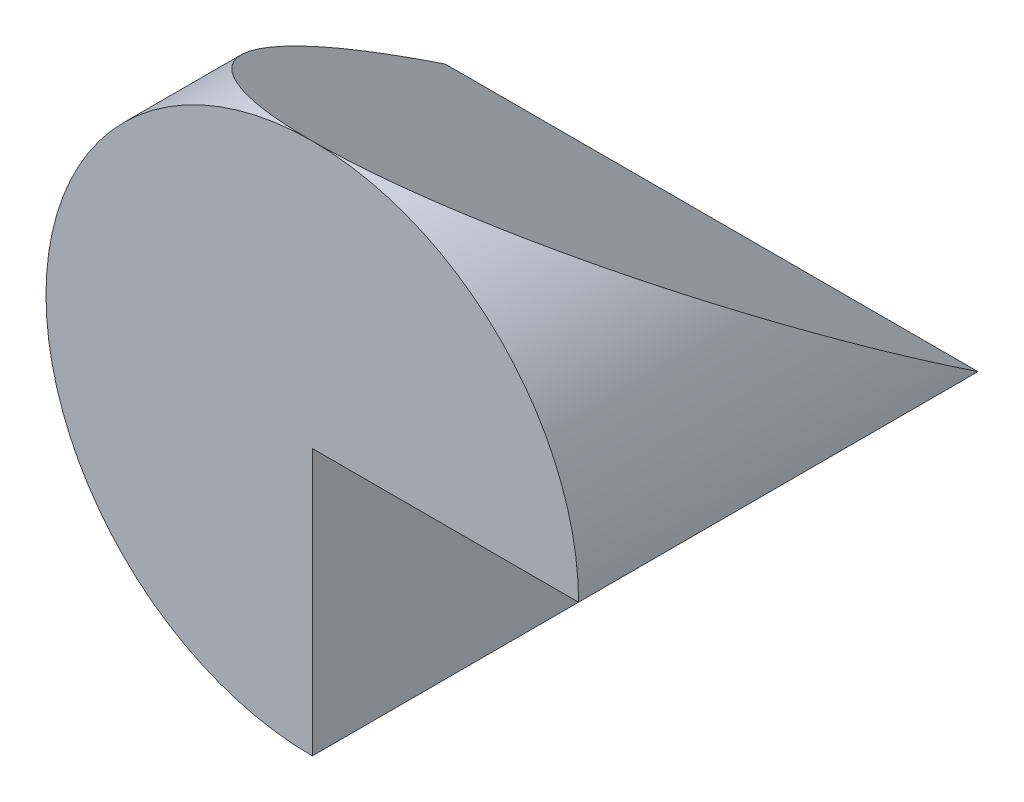
from build123d import *

# Parameters (mm, degrees)
SKETCH1_R           = 10
BOSS_EXTRUDE1_DEPTH = 15
CUT_EXTRUDE1_DEPTH  = 16
CUT_EXTRUDE2_DEPTH  = 10
CUT_EXTRUDE3_DEPTH  = 10


with BuildPart() as part:
    # Sketch1 → Boss-Extrude1 (new body)
    with BuildSketch(Plane.XY):
        Circle(SKETCH1_R)
    extrude(amount=BOSS_EXTRUDE1_DEPTH)

    # Sketch2 → Cut-Extrude1 (cut, through all)
    with BuildSketch(Plane.XY.offset(15)):
        with BuildLine():
            Line((0, 0), (10, 0))
            ThreePointArc((10, 0), (7.071067812, -7.071067812), (0, -10))
            Line((0, -10), (0, 0))
        make_face()
    extrude(amount=-CUT_EXTRUDE1_DEPTH, mode=Mode.SUBTRACT)

    # Sketch5 → Cut-Extrude2 (cut)
    with BuildSketch(Plane(origin=(10, 0, 0), x_dir=(0, 0, -1), z_dir=(1, 0, 0))):
        Polygon((0, 0), (0, 10), (-15, 10), align=None)
    extrude(amount=-CUT_EXTRUDE2_DEPTH, mode=Mode.SUBTRACT)

    # Sketch6 → Cut-Extrude3 (cut)
    with BuildSketch(Plane(origin=(0, 0, 0), x_dir=(0, 0, -1), z_dir=(1, 0, 0))):
        Polygon((-15, 10), (0, 0), (0, 10), align=None)
    extrude(amount=-CUT_EXTRUDE3_DEPTH, mode=Mode.SUBTRACT)


solid = part.part
